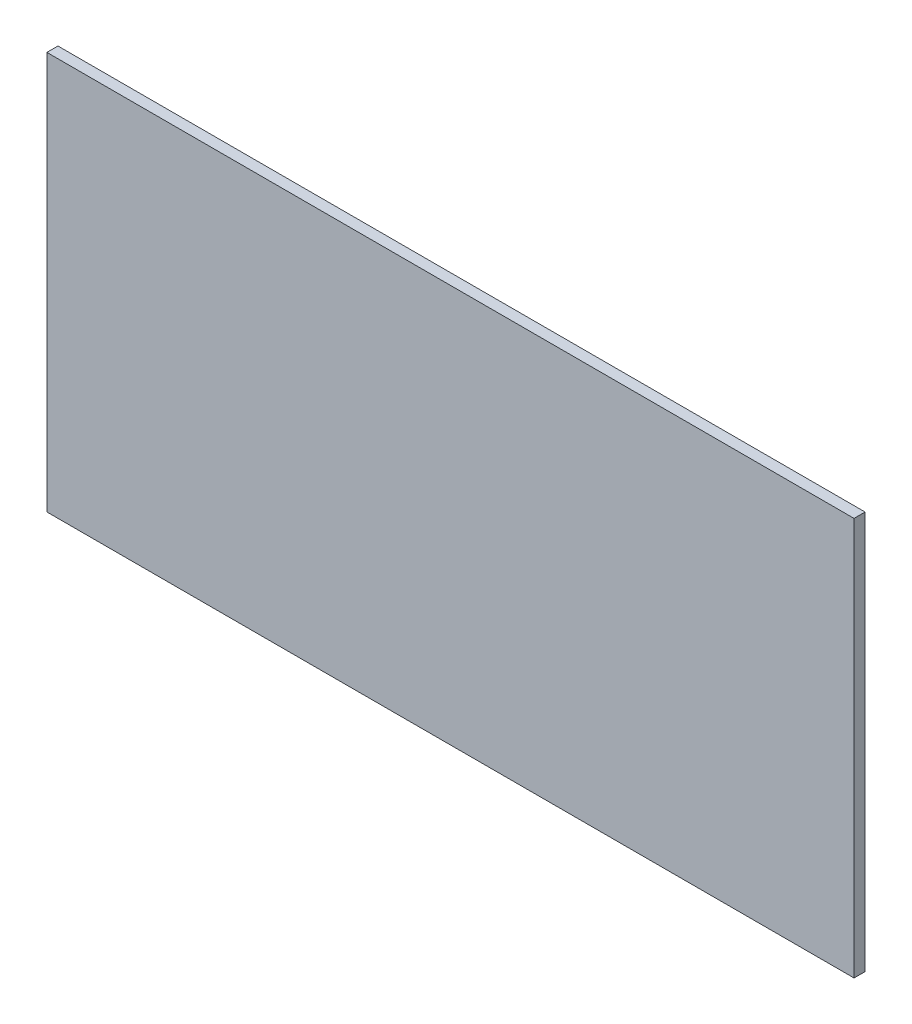
from build123d import *

# Parameters (mm, degrees)
SKETCH1_W           = 73
SKETCH1_H           = 36
BOSS_EXTRUDE1_DEPTH = 1


with BuildPart() as part:
    # Sketch1 → Boss-Extrude1 (new body)
    with BuildSketch(Plane.XY):
        with Locations((32.85, -16.2)):
            Rectangle(SKETCH1_W, SKETCH1_H)
    extrude(amount=BOSS_EXTRUDE1_DEPTH)


solid = part.part
